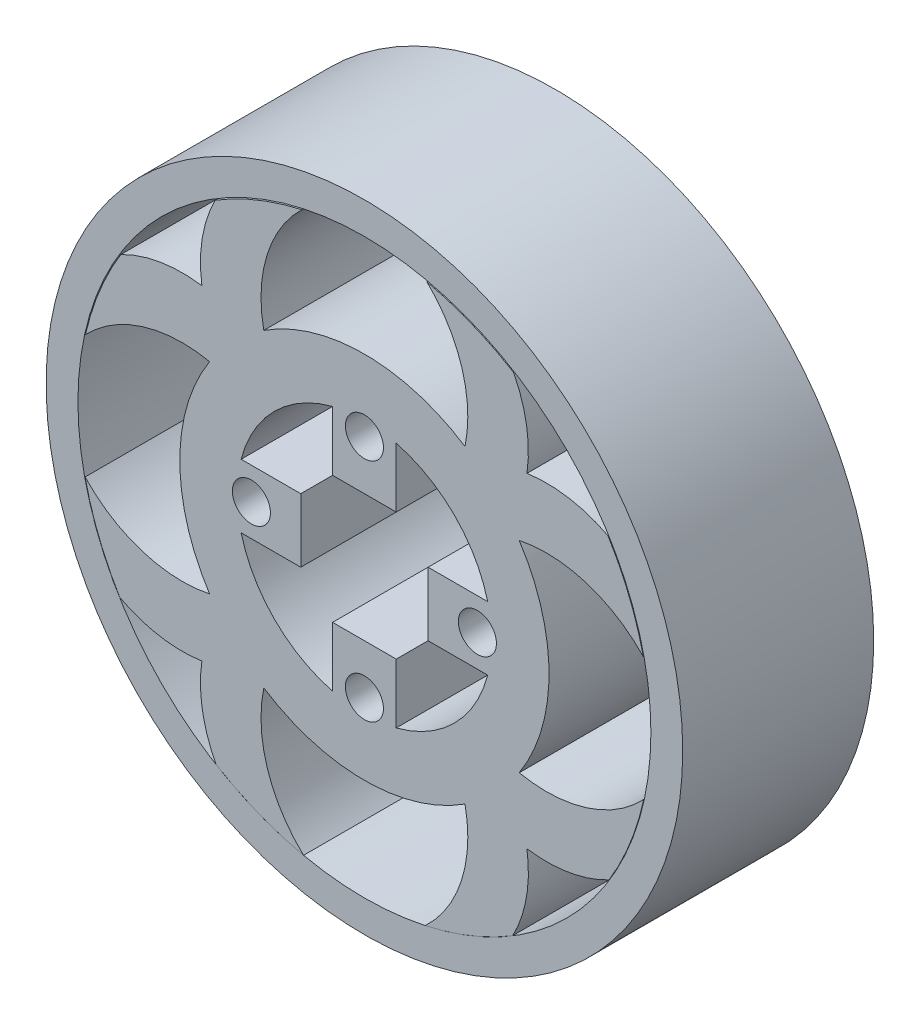
from build123d import *

# Parameters (mm, degrees)
SKETCH6_R                        = 29
SKETCH6_R_2                      = 20
INNER_RING_DEPTH                 = 30
MOTOR_CONNECTOR_CUT_DEPTH        = 30
SKETCH9_R                        = 50
SKETCH9_R_2                      = 29
OUTSIDE_RING_EXTRUSION_DEPTH     = 30
SKETCH12_R                       = 45
SKETCH12_R_2                     = 27.5
CUT_EXTRUDE6_DEPTH               = 38
CUT_EXTRUDE6_DEPTH_BACK          = 56
SKETCH8_R                        = 2.987
MOTOR_CONNECTOR_HOLES_DEPTH      = 27
MOTOR_CONNECTOR_HOLES_DEPTH_BACK = 41
SKETCH10_R                       = 27.404299948
PATTERN_DEPTH                    = 30


with BuildPart() as part:
    # Sketch6 → Inner Ring (new body)
    with BuildSketch(Plane.XY):
        Circle(SKETCH6_R)
        Circle(SKETCH6_R_2, mode=Mode.SUBTRACT)
    extrude(amount=-INNER_RING_DEPTH)

    # Sketch7 → Motor Connector Cut (add)
    with BuildSketch(Plane.XY):
        with BuildLine():
            ThreePointArc((20, 0), (19.840593925, 2.52008585), (19.364916731, 5))
            Line((19.364916731, 5), (9.999996731, 5))
            Line((9.999996731, 5), (9.999996731, -5))
            Line((9.999996731, -5), (19.364916731, -5))
            ThreePointArc((19.364916731, -5), (19.840593925, -2.52008585), (20, 0))
        make_face()
        with BuildLine():
            ThreePointArc((5, 19.364916731), (0, 20), (-5, 19.364916731))
            Line((-5, 19.364916731), (-5, 9.999996731))
            Line((-5, 9.999996731), (5, 9.999996731))
            Line((5, 9.999996731), (5, 19.364916731))
        make_face()
        with BuildLine():
            Line((-9.999996731, -5), (-9.999996731, 5))
            Line((-9.999996731, 5), (-19.364916731, 5))
            ThreePointArc((-19.364916731, 5), (-20, 0), (-19.364916731, -5))
            Line((-19.364916731, -5), (-9.999996731, -5))
        make_face()
        with BuildLine():
            Line((-5, -9.999996731), (-5, -19.364916731))
            ThreePointArc((-5, -19.364916731), (0, -20), (5, -19.364916731))
            Line((5, -19.364916731), (5, -9.999996731))
            Line((5, -9.999996731), (-5, -9.999996731))
        make_face()
    extrude(amount=-MOTOR_CONNECTOR_CUT_DEPTH)

    # Sketch9 → Outside Ring Extrusion (add)
    with BuildSketch(Plane.XY):
        Circle(SKETCH9_R)
        Circle(SKETCH9_R_2, mode=Mode.SUBTRACT)
    extrude(amount=-OUTSIDE_RING_EXTRUSION_DEPTH)

    # Sketch12 → Cut-Extrude6 (cut, two sides)
    with BuildSketch(Plane.XY) as cut_extrude6_sk:
        Circle(SKETCH12_R)
        Circle(SKETCH12_R_2, mode=Mode.SUBTRACT)
    extrude(amount=CUT_EXTRUDE6_DEPTH, mode=Mode.SUBTRACT)
    extrude(cut_extrude6_sk.sketch, amount=-CUT_EXTRUDE6_DEPTH_BACK, mode=Mode.SUBTRACT)

    # Sketch8 → Motor Connector Holes (cut, two sides)
    with BuildSketch(Plane.XY) as motor_connector_holes_sk:
        with Locations((0, 17.75)):
            Circle(SKETCH8_R)
        with Locations((17.75, 0)):
            Circle(SKETCH8_R)
        with Locations((0, -17.75)):
            Circle(SKETCH8_R)
        with Locations((-17.75, 0)):
            Circle(SKETCH8_R)
    extrude(amount=MOTOR_CONNECTOR_HOLES_DEPTH, mode=Mode.SUBTRACT)
    extrude(motor_connector_holes_sk.sketch, amount=-MOTOR_CONNECTOR_HOLES_DEPTH_BACK, mode=Mode.SUBTRACT)

    # Sketch10 → Pattern (add)
    with BuildSketch(Plane.XY):
        with BuildLine():
            ThreePointArc((24.317625284, 15.800414568), (34.856582319, 15.291767932), (43.817916626, 9.721954269))
            ThreePointArc((43.817916626, 9.721954269), (41.607188912, 16.793289988), (38.263814419, 23.404867172))
            ThreePointArc((38.263814419, 23.404867172), (32.064348025, 25.470287935), (25.530148518, 25.530148518))
            ThreePointArc((25.530148518, 25.530148518), (25.475284033, 32.034279432), (23.432821057, 38.209639668))
            ThreePointArc((23.432821057, 38.209639668), (20.212556871, 40.002288656), (16.856128399, 41.524812789))
            ThreePointArc((16.856128399, 41.524812789), (13.384732217, 42.767397097), (9.823095744, 43.720997037))
            ThreePointArc((9.823095744, 43.720997037), (15.312499865, 34.789679765), (15.800414568, 24.317625284))
            ThreePointArc((15.800414568, 24.317625284), (0, 29), (-15.800414568, 24.317625284))
            ThreePointArc((-15.800414568, 24.317625284), (-15.312499865, 34.789679765), (-9.823095744, 43.720997037))
            ThreePointArc((-9.823095744, 43.720997037), (-16.854754984, 41.52536899), (-23.432821057, 38.209639668))
            ThreePointArc((-23.432821057, 38.209639668), (-25.475284033, 32.034279432), (-25.530148518, 25.530148518))
            ThreePointArc((-25.530148518, 25.530148518), (-32.064348025, 25.470287935), (-38.263814419, 23.404867172))
            ThreePointArc((-38.263814419, 23.404867172), (-41.607188912, 16.793289988), (-43.817916626, 9.721954269))
            ThreePointArc((-43.817916626, 9.721954269), (-34.856582319, 15.291767932), (-24.317625284, 15.800414568))
            ThreePointArc((-24.317625284, 15.800414568), (-29, 0), (-24.317625284, -15.800414568))
            ThreePointArc((-24.317625284, -15.800414568), (-34.894848495, -15.279799844), (-43.87309253, -9.663767027))
            ThreePointArc((-43.87309253, -9.663767027), (-41.716263612, -16.713446711), (-38.435015504, -23.315212041))
            ThreePointArc((-38.435015504, -23.315212041), (-32.159621016, -25.454161245), (-25.530148518, -25.530148518))
            ThreePointArc((-25.530148518, -25.530148518), (-25.448803812, -32.190695038), (-23.285614603, -38.490703716))
            ThreePointArc((-23.285614603, -38.490703716), (-16.649731385, -41.799208281), (-9.559859326, -43.970581744))
            ThreePointArc((-9.559859326, -43.970581744), (-15.258354287, -34.962784804), (-15.800414568, -24.317625284))
            ThreePointArc((-15.800414568, -24.317625284), (0, -29), (15.800414568, -24.317625284))
            ThreePointArc((15.800414568, -24.317625284), (15.258354287, -34.962784804), (9.559859326, -43.970581744))
            ThreePointArc((9.559859326, -43.970581744), (16.649731385, -41.799208281), (23.285614603, -38.490703716))
            ThreePointArc((23.285614603, -38.490703716), (25.448803812, -32.190695038), (25.530148518, -25.530148518))
            ThreePointArc((25.530148518, -25.530148518), (32.159621016, -25.454161245), (38.435015504, -23.315212041))
            ThreePointArc((38.435015504, -23.315212041), (41.716263612, -16.713446711), (43.87309253, -9.663767027))
            ThreePointArc((43.87309253, -9.663767027), (34.894848495, -15.279799844), (24.317625284, -15.800414568))
            ThreePointArc((24.317625284, -15.800414568), (29, 0), (24.317625284, 15.800414568))
        make_face()
        with Locations((-0.095700052, 0)):
            Circle(SKETCH10_R, mode=Mode.SUBTRACT)
    extrude(amount=-PATTERN_DEPTH)


solid = part.part
